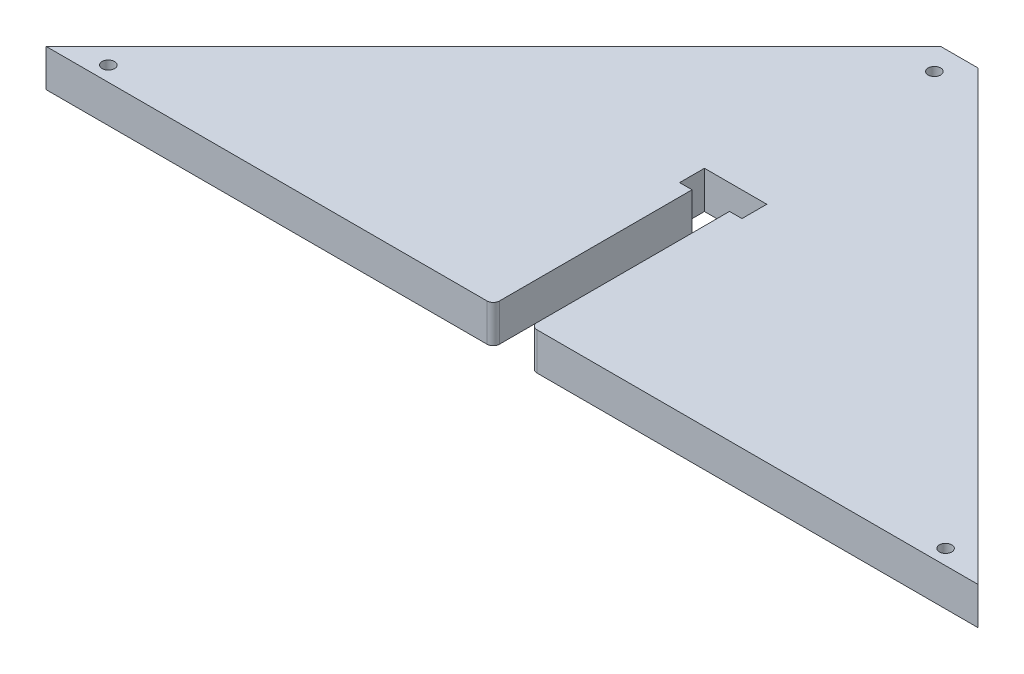
from build123d import *

# Parameters (mm, degrees)
SKETCH2_R           = 3
BOSS_EXTRUDE1_DEPTH = 18.1


with BuildPart() as part:
    # Sketch2 → Boss-Extrude1 (new body)
    with BuildSketch(Plane(origin=(0, 0, 0), x_dir=(1, 0, 0), z_dir=(0, 1, 0))):
        with BuildLine():
            Line((-191.397338403, -33.450570342), (21.552661597, -33.450570342))
            ThreePointArc((21.552661597, -33.450570342), (23.673981941, -32.571890686), (24.552661597, -30.450570342))
            Line((24.552661597, -30.450570342), (24.552661597, 62.524429658))
            Line((24.552661597, 62.524429658), (18.552661597, 62.524429658))
            Line((18.552661597, 62.524429658), (18.552661597, 74.524429658))
            Line((18.552661597, 74.524429658), (24.552661597, 74.524429658))
            Line((24.552661597, 74.524429658), (42.652661597, 74.524429658))
            Line((42.652661597, 74.524429658), (48.652661597, 74.524429658))
            Line((48.652661597, 74.524429658), (48.652661597, 62.524429658))
            Line((48.652661597, 62.524429658), (42.652661597, 62.524429658))
            Line((42.652661597, 62.524429658), (42.652661597, -30.450570342))
            ThreePointArc((42.652661597, -30.450570342), (43.531341253, -32.571890686), (45.652661597, -33.450570342))
            Line((45.652661597, -33.450570342), (258.602661597, -33.450570342))
            Line((258.602661597, -33.450570342), (42.652661597, 182.499429658))
            Line((42.652661597, 182.499429658), (24.552661597, 182.499429658))
            Line((24.552661597, 182.499429658), (-191.397338403, -33.450570342))
        make_face()
        with Locations((33.602661597, 170.499429658)):
            Circle(SKETCH2_R, mode=Mode.SUBTRACT)
        with Locations((235.716045652, -26.225419091)):
            Circle(SKETCH2_R, mode=Mode.SUBTRACT)
        with Locations((-168.510722458, -26.225419091)):
            Circle(SKETCH2_R, mode=Mode.SUBTRACT)
    extrude(amount=BOSS_EXTRUDE1_DEPTH)


solid = part.part
